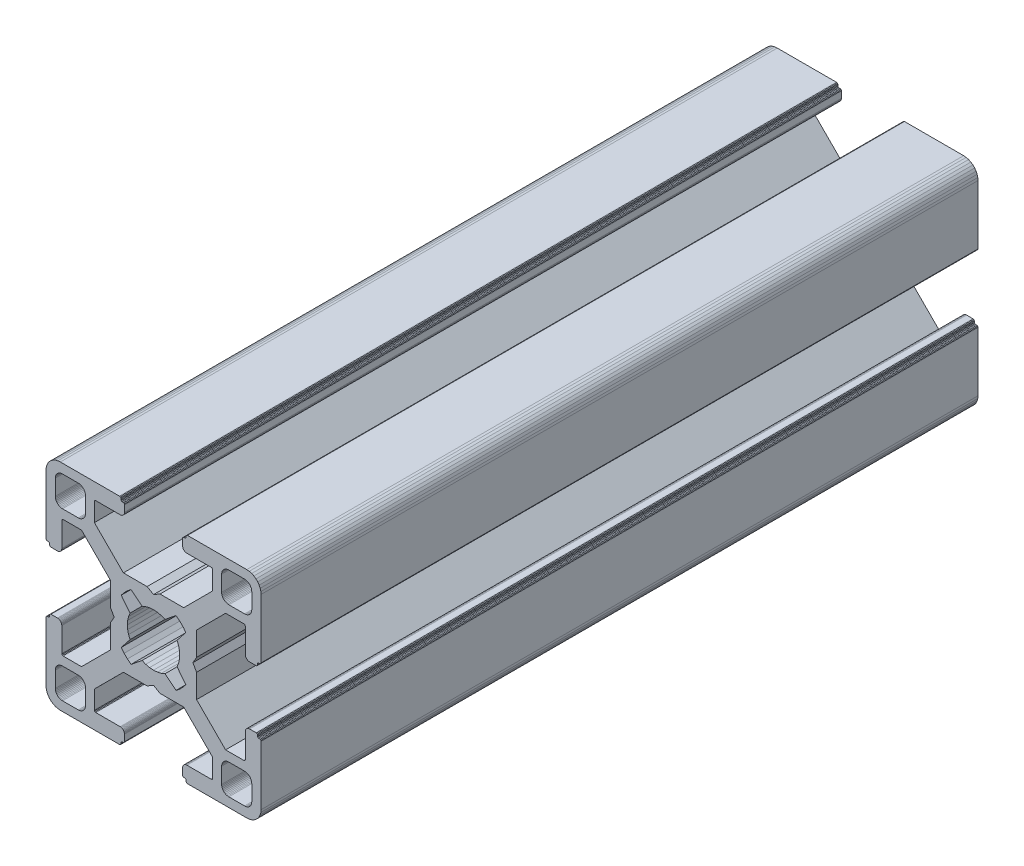
from build123d import *

# Parameters (mm, degrees)
BOSS_EXTRUDE1_DEPTH = 100


with BuildPart() as part:
    # Sketch1 → Boss-Extrude1 (new body)
    with BuildSketch(Plane.XY):
        Polygon((28.34729664, 29.969613999), (28.000000864, 29.999999329), (19.750000909, 29.999999329), (19.715268165, 29.996961355), (19.681595266, 29.987938702), (19.649999216, 29.973205179), (19.621443003, 29.953207821), (19.596790895, 29.928557575), (19.576793537, 29.899999499), (19.562061876, 29.868405312), (19.55303736, 29.834728688), (19.549999386, 29.799999669), (19.549999386, 29.699999839), (19.546961412, 29.665268958), (19.537936896, 29.631596059), (19.523203373, 29.599998146), (19.503207877, 29.571441934), (19.478557631, 29.546789825), (19.449999556, 29.526794329), (19.418403506, 29.512060806), (19.384728745, 29.503038153), (19.349999726, 29.500000179), (19.249999896, 29.500000179), (19.215267517, 29.496958527), (19.181592755, 29.487935874), (19.149996706, 29.47320235), (19.12143863, 29.453206855), (19.096788384, 29.428554746), (19.076791026, 29.399996671), (19.062057503, 29.368402484), (19.05303485, 29.334725859), (19.049996876, 29.299998703), (19.049996876, 28.39999837), (19.059110798, 28.29580945), (19.08618062, 28.194785165), (19.13038119, 28.099997016), (19.190369539, 28.014324653), (19.264324002, 27.94037019), (19.349996366, 27.88038184), (19.444784515, 27.836181271), (19.545806937, 27.809111449), (19.650010894, 27.799984574), (23.050010706, 27.799984574), (23.084741588, 27.7969466), (23.118414487, 27.787923946), (23.150012399, 27.773190423), (23.178568612, 27.753193065), (23.203220721, 27.728542819), (23.223218079, 27.699984744), (23.237949739, 27.668386831), (23.246974255, 27.634713932), (23.25001142, 27.59998608), (23.25001142, 25.049987618), (19.204474482, 20.999982084), (15.900007876, 20.999982084), (15.000008474, 20.48483404), (14.10000814, 20.999982084), (10.795543398, 20.999982084), (7.997342887, 23.801274731), (6.750011387, 25.049984589), (6.750011387, 27.599983051), (6.753049362, 27.634713932), (6.762072946, 27.668386831), (6.776805538, 27.699984744), (6.796801965, 27.728542819), (6.821454073, 27.753193065), (6.850011218, 27.773190423), (6.881607267, 27.787923946), (6.915282029, 27.7969466), (6.950011048, 27.799984574), (10.350011791, 27.799984574), (10.45420071, 27.809098497), (10.555223133, 27.836168318), (10.650011282, 27.880368888), (10.735683645, 27.940357238), (10.809638108, 28.014311701), (10.869626458, 28.099984064), (10.913827027, 28.194772213), (10.940895918, 28.295796498), (10.950010772, 28.399985417), (10.950010772, 29.299985751), (10.946974575, 29.334739239), (10.93795065, 29.368415522), (10.923215933, 29.400009153), (10.903218427, 29.428566473), (10.878566319, 29.45321765), (10.849999264, 29.473204166), (10.818403214, 29.487937689), (10.784728453, 29.496960342), (10.749999434, 29.500000179), (10.649999604, 29.500000179), (10.615270585, 29.503038153), (10.581595823, 29.512060806), (10.549999774, 29.526794329), (10.521441698, 29.546789825), (10.496791452, 29.571441934), (10.476795025, 29.599998146), (10.462061502, 29.631596059), (10.453037918, 29.665268958), (10.449999943, 29.699999839), (10.449999943, 29.799999669), (10.446961969, 29.834728688), (10.437938385, 29.868405312), (10.423205793, 29.899999499), (10.403208435, 29.928557575), (10.378557257, 29.953207821), (10.350000113, 29.973205179), (10.318404064, 29.987938702), (10.284729302, 29.996961355), (10.250000283, 29.999999329), (1.999999397, 29.999999329), (1.652702689, 29.969613999), (1.315958682, 29.879383743), (0.999999233, 29.732050374), (0.714424066, 29.532089829), (0.467910431, 29.285576195), (0.267948955, 28.999999166), (0.120614655, 28.684040532), (0.030384399, 28.34729664), (0, 28.000000864), (0, 19.750000909), (0.003037974, 19.715268165), (0.012061559, 19.681595266), (0.026795082, 19.649999216), (0.046790577, 19.621441141), (0.071442686, 19.596789032), (0.09999983, 19.576793537), (0.13159588, 19.562060013), (0.165270641, 19.55303736), (0.19999966, 19.549999386), (0.299999461, 19.549999386), (0.334728509, 19.546959549), (0.368403242, 19.537936896), (0.399999321, 19.523203373), (0.428556465, 19.503207877), (0.453208573, 19.478555769), (0.473204069, 19.449997693), (0.487937592, 19.418403506), (0.496961176, 19.384728745), (0.499999151, 19.349999726), (0.499999151, 19.249998033), (0.503038056, 19.215269014), (0.512060709, 19.181594253), (0.526794232, 19.150000066), (0.546790194, 19.121441524), (0.571441837, 19.096789882), (0.60000029, 19.076794925), (0.631595686, 19.062061999), (0.665270619, 19.053039982), (0.700000626, 19.050000801), (1.60000096, 19.050000801), (1.704189879, 19.059116587), (1.805213233, 19.086186409), (1.90000045, 19.130385115), (1.985673745, 19.190375328), (2.059627277, 19.264327928), (2.119616325, 19.350002154), (2.163816196, 19.444788441), (2.190886018, 19.545812726), (2.200000872, 19.650001645), (2.200000872, 23.050001457), (2.203039777, 23.084732338), (2.212062431, 23.118405237), (2.226795954, 23.15000315), (2.246792381, 23.178559362), (2.271443558, 23.203211471), (2.300000702, 23.223206967), (2.331596752, 23.23794049), (2.365271513, 23.246965006), (2.400001464, 23.250001117), (4.950000857, 23.250001117), (7.997332093, 20.202670812), (8.995535423, 19.204467788), (8.995535423, 15.900001182), (9.515148227, 15.00000178), (8.995535423, 14.100002378), (8.995535423, 10.795536704), (4.950000857, 6.750002138), (2.400001464, 6.750002138), (2.365271513, 6.753040112), (2.331596752, 6.762063697), (2.300000702, 6.77679722), (2.271443558, 6.796793647), (2.246792381, 6.821444824), (2.226795954, 6.850001968), (2.212062431, 6.881598018), (2.203039777, 6.915272779), (2.200000872, 6.950002729), (2.200000872, 10.350002542), (2.190896812, 10.454174265), (2.16382699, 10.555197618), (2.119627119, 10.649984836), (2.059638071, 10.735658131), (1.985684539, 10.809611663), (1.900011244, 10.869600944), (1.805224027, 10.913800582), (1.704200673, 10.940870404), (1.600011754, 10.949986189), (0.70001142, 10.949986189), (0.665281355, 10.946948596), (0.631606253, 10.937926283), (0.600010578, 10.923193954), (0.571451747, 10.903199537), (0.546799638, 10.87854836), (0.526794232, 10.850000195), (0.512060709, 10.818404146), (0.503038056, 10.784730315), (0.499999151, 10.750000365), (0.499999151, 10.650000535), (0.496961176, 10.615270585), (0.487937592, 10.581596754), (0.473204069, 10.550000705), (0.453208573, 10.521443561), (0.428556465, 10.496791452), (0.399999321, 10.476795956), (0.368403242, 10.462062433), (0.334728509, 10.453038849), (0.299999461, 10.449999943), (0.19999966, 10.449999943), (0.165270641, 10.446961969), (0.13159588, 10.437939316), (0.09999983, 10.423205793), (0.071442686, 10.403209366), (0.046790577, 10.378558189), (0.026795082, 10.350000113), (0.012061559, 10.318404064), (0.003037974, 10.284729302), (0, 10.250000283), (0, 1.999999397), (0.030384399, 1.652702689), (0.120614655, 1.315958682), (0.267948955, 0.999999233), (0.467910431, 0.714424066), (0.714424066, 0.467910431), (0.999999233, 0.267948955), (1.315958682, 0.120614655), (1.652702689, 0.030384399), (1.999999397, 0), (10.250000283, 0), (10.284729302, 0.003037974), (10.318404064, 0.012061559), (10.350000113, 0.026795082), (10.378557257, 0.046790577), (10.403208435, 0.071442686), (10.423205793, 0.09999983), (10.437938385, 0.13159588), (10.446961969, 0.165270641), (10.449999943, 0.19999966), (10.449999943, 0.300000422), (10.453037918, 0.334729441), (10.462061502, 0.368404202), (10.476795025, 0.400000252), (10.496791452, 0.428557396), (10.521441698, 0.453208573), (10.549999774, 0.473205), (10.581595823, 0.487938523), (10.615270585, 0.496961176), (10.649999604, 0.500000082), (10.749999434, 0.500000082), (10.784728453, 0.503038056), (10.818403214, 0.512060709), (10.849999264, 0.526794232), (10.878547894, 0.546800104), (10.903198606, 0.571451747), (10.923194493, 0.6000102), (10.93792742, 0.631606528), (10.946949437, 0.66528146), (10.950010772, 0.699984975), (10.950010772, 1.599985308), (10.940895918, 1.704174228), (10.913827027, 1.805197581), (10.869626458, 1.89998573), (10.809638108, 1.985658094), (10.735683645, 2.059612557), (10.650011282, 2.119600674), (10.555223133, 2.163801476), (10.45420071, 2.190870367), (10.350011791, 2.199985221), (6.950011048, 2.199985221), (6.915282029, 2.203024126), (6.881607267, 2.212046779), (6.850011218, 2.226780302), (6.821454073, 2.246776729), (6.796801965, 2.271427907), (6.776805538, 2.299985982), (6.762072946, 2.331582032), (6.753049362, 2.365256793), (6.750011387, 2.399985812), (6.750011387, 4.949985206), (9.787457566, 7.990785077), (10.795545277, 8.999985833), (14.100010019, 8.999985833), (15.000010353, 9.515133877), (15.900009756, 8.999985833), (19.204476361, 8.999985833), (20.21256413, 7.990786065), (23.25001142, 4.949988235), (23.25001142, 2.399988841), (23.246974255, 2.365256793), (23.237949739, 2.331582032), (23.223218079, 2.299985982), (23.203220721, 2.271427907), (23.178568612, 2.246776729), (23.150012399, 2.226780302), (23.118414487, 2.212046779), (23.084741588, 2.203024126), (23.050010706, 2.199985221), (19.650010894, 2.199985221), (19.545806937, 2.190883319), (19.444784515, 2.163814428), (19.349996366, 2.119613626), (19.264324002, 2.059625509), (19.190369539, 1.985671046), (19.13038119, 1.899998682), (19.08618062, 1.805210533), (19.059110798, 1.70418718), (19.049996876, 1.599998261), (19.049996876, 0.699997927), (19.053035506, 0.665268966), (19.062058795, 0.631594374), (19.076792915, 0.599998603), (19.096790813, 0.571440905), (19.121441524, 0.546790194), (19.149999978, 0.526794306), (19.181596306, 0.51206138), (19.215271238, 0.503039363), (19.249999896, 0.500000082), (19.349999726, 0.500000082), (19.384728745, 0.496961176), (19.418403506, 0.487938523), (19.449999556, 0.473205), (19.478557631, 0.453208573), (19.503207877, 0.428557396), (19.523203373, 0.400000252), (19.537936896, 0.368404202), (19.546961412, 0.334729441), (19.549999386, 0.300000422), (19.549999386, 0.19999966), (19.55303736, 0.165270641), (19.562061876, 0.13159588), (19.576793537, 0.09999983), (19.596789964, 0.071441755), (19.621442072, 0.046789646), (19.649998285, 0.02679415), (19.681594335, 0.012060627), (19.715267234, 0.003037043), (19.750000909, 0), (28.000000864, 0), (28.34729664, 0.030384399), (28.684040532, 0.120614655), (28.999999166, 0.267948955), (29.285576195, 0.467910431), (29.532089829, 0.714424066), (29.732050374, 0.999999233), (29.879383743, 1.315958682), (29.969613999, 1.652702689), (29.999999329, 1.999999397), (29.999999329, 10.250000283), (29.996974806, 10.284715361), (29.987951516, 10.318389952), (29.973217396, 10.349985723), (29.953219499, 10.378543421), (29.928568787, 10.403194133), (29.899999499, 10.423205793), (29.868405312, 10.437939316), (29.834728688, 10.446961969), (29.799999669, 10.449999943), (29.699999839, 10.449999943), (29.664909937, 10.453400043), (29.631233313, 10.462423628), (29.599637263, 10.477157151), (29.57108105, 10.497152646), (29.546427079, 10.521804755), (29.526433446, 10.550361899), (29.511699923, 10.581957949), (29.502675407, 10.615631779), (29.499637433, 10.650361729), (29.499637433, 10.750361559), (29.49697202, 10.784715548), (29.487949367, 10.818389378), (29.473215844, 10.849985428), (29.453220348, 10.878542572), (29.428568239, 10.90319468), (29.400010164, 10.923190176), (29.368415977, 10.937923699), (29.334741215, 10.946947284), (29.300012197, 10.949986189), (28.400011863, 10.949986189), (28.29581215, 10.9408876), (28.194787865, 10.913817778), (28.099999716, 10.86961814), (28.014327352, 10.809628859), (27.940374752, 10.735675327), (27.880384539, 10.650002032), (27.836185833, 10.555214814), (27.809114148, 10.454191461), (27.800000225, 10.350002542), (27.800000225, 6.950002729), (27.796962251, 6.915272779), (27.787939598, 6.881598018), (27.773206075, 6.850001968), (27.753208716, 6.821444824), (27.728558471, 6.796793647), (27.700000395, 6.77679722), (27.668404345, 6.762063697), (27.634729584, 6.753040112), (27.599998702, 6.750002138), (25.05000024, 6.750002138), (23.809199132, 7.99080223), (21.004464477, 10.795534588), (21.004464477, 14.100000262), (20.484851673, 14.999999665), (21.004464477, 15.899999067), (21.004464477, 19.204465672), (25.05000024, 23.250001117), (27.599998702, 23.250001117), (27.634729584, 23.246965006), (27.668404345, 23.23794049), (27.700000395, 23.223206967), (27.728558471, 23.203211471), (27.753208716, 23.178559362), (27.773206075, 23.15000315), (27.787939598, 23.118405237), (27.796962251, 23.084732338), (27.800000225, 23.050001457), (27.800000225, 19.650001645), (27.809114148, 19.545812726), (27.836185833, 19.444788441), (27.880384539, 19.350002154), (27.940370508, 19.264323684), (28.014323108, 19.190371084), (28.099995472, 19.130380872), (28.194783621, 19.086182165), (28.295807906, 19.059112343), (28.400001069, 19.050000801), (29.300001402, 19.050000801), (29.334730421, 19.053040638), (29.368405183, 19.062063291), (29.39999937, 19.076796814), (29.42819671, 19.097149726), (29.452848353, 19.1218023), (29.472843309, 19.150360754), (29.487576235, 19.181955219), (29.496598252, 19.215630151), (29.499637433, 19.250359227), (29.499637433, 19.35036092), (29.502675407, 19.385089939), (29.511699923, 19.4187647), (29.526433446, 19.450358887), (29.546427079, 19.478916963), (29.57108105, 19.503569071), (29.599637263, 19.523564567), (29.631233313, 19.53829809), (29.664909937, 19.547320743), (29.699999839, 19.549999386), (29.799999669, 19.549999386), (29.834728688, 19.55303736), (29.868405312, 19.562060013), (29.899999499, 19.576793537), (29.928557575, 19.596789032), (29.953207821, 19.621441141), (29.973205179, 19.649999216), (29.987938702, 19.681595266), (29.996961355, 19.715268165), (29.999999329, 19.750000909), (29.999999329, 28.000000864), (29.969613999, 28.34729664), (29.879383743, 28.684040532), (29.732050374, 28.999999166), (29.532089829, 29.285576195), (29.285576195, 29.532089829), (28.999999166, 29.732050374), (28.684040532, 29.879383743), align=None)
        Polygon((1.299998723, 25.499999523), (1.299998723, 27.699999511), (1.312309876, 27.856435627), (1.348942518, 28.009016067), (1.408992335, 28.153989464), (1.490981318, 28.287785128), (1.592892222, 28.407108039), (1.71221327, 28.50901708), (1.846008119, 28.591006994), (1.9909814, 28.651056811), (2.143563703, 28.687689453), (2.299998887, 28.699999675), (4.499998875, 28.699999675), (4.656434059, 28.687689453), (4.809016362, 28.651056811), (4.953989759, 28.591006994), (5.087784491, 28.50901708), (5.207106471, 28.407108039), (5.309016444, 28.287785128), (5.391005427, 28.153989464), (5.451056175, 28.009016067), (5.487687886, 27.856435627), (5.499999039, 27.699999511), (5.499999039, 25.499999523), (5.487687886, 25.34356527), (5.451056175, 25.190982968), (5.391005427, 25.04600957), (5.309016444, 24.912213907), (5.207106471, 24.792892858), (5.087784491, 24.690981954), (4.953989759, 24.60899204), (4.809016362, 24.548944086), (4.656434059, 24.512309581), (4.499998875, 24.499999359), (2.299998887, 24.499999359), (2.143563703, 24.512309581), (1.9909814, 24.548944086), (1.846008119, 24.60899204), (1.71221327, 24.690981954), (1.592892222, 24.792892858), (1.490981318, 24.912213907), (1.408992335, 25.04600957), (1.348942518, 25.190982968), (1.312309876, 25.34356527), align=None, mode=Mode.SUBTRACT)
        Polygon((25.34356527, 28.687689453), (25.499999523, 28.699999675), (27.699999511, 28.699999675), (27.856435627, 28.687689453), (28.009017929, 28.651056811), (28.153991327, 28.591006994), (28.28778699, 28.50901708), (28.407108039, 28.407108039), (28.50901708, 28.287785128), (28.591006994, 28.153989464), (28.651056811, 28.009016067), (28.687689453, 27.856435627), (28.700001538, 27.699999511), (28.700001538, 25.499999523), (28.687689453, 25.34356527), (28.651056811, 25.190982968), (28.591006994, 25.04600957), (28.50901708, 24.912213907), (28.407108039, 24.792892858), (28.28778699, 24.690981954), (28.153991327, 24.60899204), (28.009017929, 24.548944086), (27.856435627, 24.512309581), (27.699999511, 24.499999359), (25.499999523, 24.499999359), (25.34356527, 24.512309581), (25.190982968, 24.548944086), (25.04600957, 24.60899204), (24.912215769, 24.690981954), (24.792892858, 24.792892858), (24.690981954, 24.912213907), (24.608993903, 25.04600957), (24.548944086, 25.190982968), (24.512311444, 25.34356527), (24.500001222, 25.499999523), (24.500001222, 27.699999511), (24.512311444, 27.856435627), (24.548944086, 28.009016067), (24.608993903, 28.153989464), (24.690981954, 28.287785128), (24.792892858, 28.407108039), (24.912215769, 28.50901708), (25.04600957, 28.591006994), (25.190982968, 28.651056811), align=None, mode=Mode.SUBTRACT)
        Polygon((14.999999665, 18.649999052), (15.550030395, 18.608318642), (16.087498516, 18.484227359), (16.600128263, 18.280562013), (18.13592948, 19.518401474), (18.644984812, 19.11874488), (19.103571773, 18.662061542), (19.505336881, 18.154669553), (18.280562013, 16.600130126), (18.484227359, 16.087498516), (18.608318642, 15.550030395), (18.649999052, 14.999999665), (18.608318642, 14.449968934), (18.484227359, 13.912500814), (18.280562013, 13.399870135), (19.505336881, 11.845329776), (19.103571773, 11.337937787), (18.644984812, 10.881252587), (18.13592948, 10.481598787), (16.600128263, 11.719437316), (16.087498516, 11.515771039), (15.550030395, 11.391680688), (14.999999665, 11.349999346), (14.449968934, 11.391680688), (13.912500814, 11.515771039), (13.399870135, 11.719437316), (11.864069849, 10.481598787), (11.355013587, 10.881252587), (10.896427557, 11.337937787), (10.494662449, 11.845329776), (11.719438247, 13.399870135), (11.515771039, 13.912500814), (11.391680688, 14.449968934), (11.349999346, 14.999999665), (11.391680688, 15.550030395), (11.515771039, 16.087498516), (11.719438247, 16.600130126), (10.494662449, 18.154669553), (10.896427557, 18.662061542), (11.355013587, 19.11874488), (11.864069849, 19.518401474), (13.399870135, 18.280562013), (13.912500814, 18.484227359), (14.449968934, 18.608318642), align=None, mode=Mode.SUBTRACT)
        Polygon((4.499998875, 1.299999771), (2.299998887, 1.299999771), (2.143563703, 1.312310807), (1.9909814, 1.348942518), (1.846008119, 1.408992335), (1.71221327, 1.490982249), (1.592892222, 1.592892222), (1.490981318, 1.712214202), (1.408992335, 1.846008934), (1.348942518, 1.990982331), (1.312309876, 2.143564634), (1.299998723, 2.299998887), (1.299998723, 4.499999806), (1.312309876, 4.656434059), (1.348942518, 4.809017293), (1.408992335, 4.95399069), (1.490981318, 5.087785423), (1.592892222, 5.207106471), (1.71221327, 5.309017375), (1.846008119, 5.391006358), (1.9909814, 5.451056175), (2.143563703, 5.487688817), (2.299998887, 5.49999997), (4.499998875, 5.49999997), (4.656434059, 5.487688817), (4.809016362, 5.451056175), (4.953989759, 5.391006358), (5.087784491, 5.309017375), (5.207106471, 5.207106471), (5.309016444, 5.087785423), (5.391005427, 4.95399069), (5.451056175, 4.809017293), (5.487687886, 4.656434059), (5.499999039, 4.499999806), (5.499999039, 2.299998887), (5.487687886, 2.143564634), (5.451056175, 1.990982331), (5.391005427, 1.846008934), (5.309016444, 1.712214202), (5.207106471, 1.592892222), (5.087784491, 1.490982249), (4.953989759, 1.408992335), (4.809016362, 1.348942518), (4.656434059, 1.312310807), align=None, mode=Mode.SUBTRACT)
        Polygon((27.699999511, 1.299999771), (25.499999523, 1.299999771), (25.34356527, 1.312310807), (25.190982968, 1.348942518), (25.04600957, 1.408992335), (24.912215769, 1.490982249), (24.792892858, 1.592892222), (24.690981954, 1.712214202), (24.608993903, 1.846008934), (24.548944086, 1.990982331), (24.512311444, 2.143564634), (24.500001222, 2.299998887), (24.500001222, 4.499999806), (24.512311444, 4.656434059), (24.548944086, 4.809017293), (24.608993903, 4.95399069), (24.690981954, 5.087785423), (24.792892858, 5.207106471), (24.912215769, 5.309017375), (25.04600957, 5.391006358), (25.190982968, 5.451056175), (25.34356527, 5.487688817), (25.499999523, 5.49999997), (27.699999511, 5.49999997), (27.856435627, 5.487688817), (28.009017929, 5.451056175), (28.153991327, 5.391006358), (28.28778699, 5.309017375), (28.407108039, 5.207106471), (28.50901708, 5.087785423), (28.591006994, 4.95399069), (28.651056811, 4.809017293), (28.687689453, 4.656434059), (28.700001538, 4.499999806), (28.700001538, 2.299998887), (28.687689453, 2.143564634), (28.651056811, 1.990982331), (28.591006994, 1.846008934), (28.50901708, 1.712214202), (28.407108039, 1.592892222), (28.28778699, 1.490982249), (28.153991327, 1.408992335), (28.009017929, 1.348942518), (27.856435627, 1.312310807), align=None, mode=Mode.SUBTRACT)
    extrude(amount=-BOSS_EXTRUDE1_DEPTH)


solid = part.part
